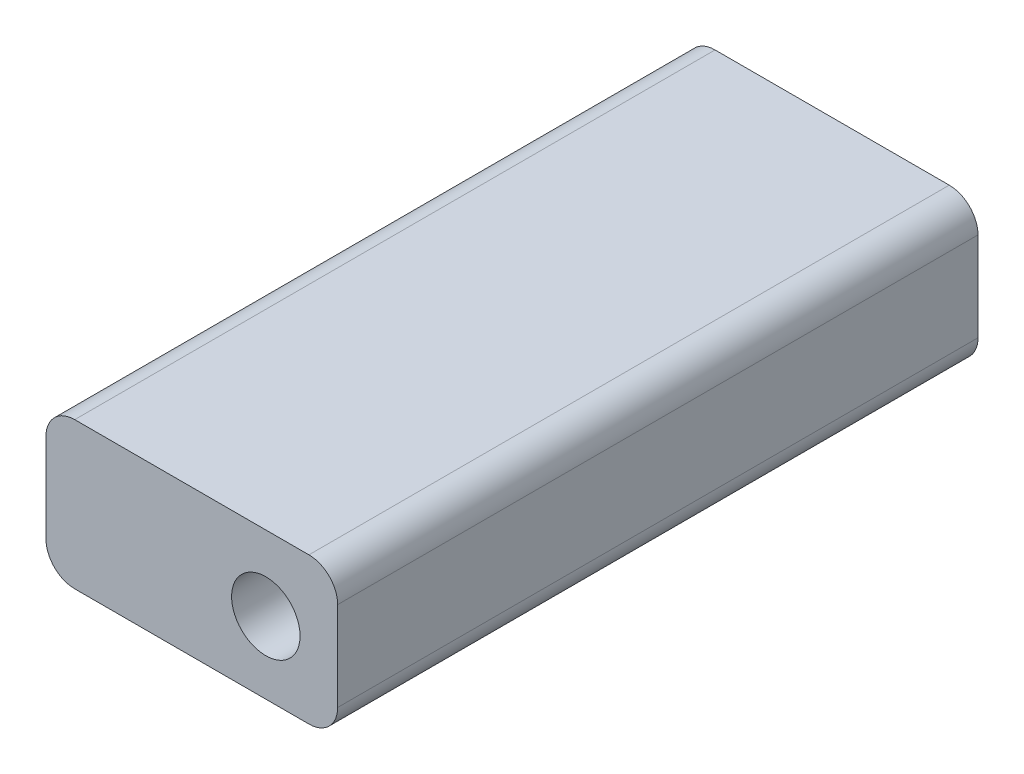
from build123d import *

# Parameters (mm, degrees)
SKETCH1_W           = 25.780000002
SKETCH1_H           = 12.954026584
SKETCH1_R           = 3.025
BOSS_EXTRUDE1_DEPTH = 56.59882
FILLET2_R           = 2.54


with BuildPart() as part:
    # Sketch1 → Boss-Extrude1 (new body)
    with BuildSketch(Plane.XY):
        with Locations((-6.540000001, 85.048986708)):
            Rectangle(SKETCH1_W, SKETCH1_H)
        with Locations((0, 84.921973416)):
            Circle(SKETCH1_R, mode=Mode.SUBTRACT)
    extrude(amount=BOSS_EXTRUDE1_DEPTH)

    # Fillet2
    fillet2_edges = [part.edges().sort_by_distance(p)[0] for p in [
        (-19.430000002, 91.526, 28.29941),
        (6.35, 91.526, 28.29941),
        (6.35, 78.571973416, 28.29941),
        (-19.430000002, 78.571973416, 28.29941),
    ]]
    fillet(fillet2_edges, radius=FILLET2_R)


solid = part.part
